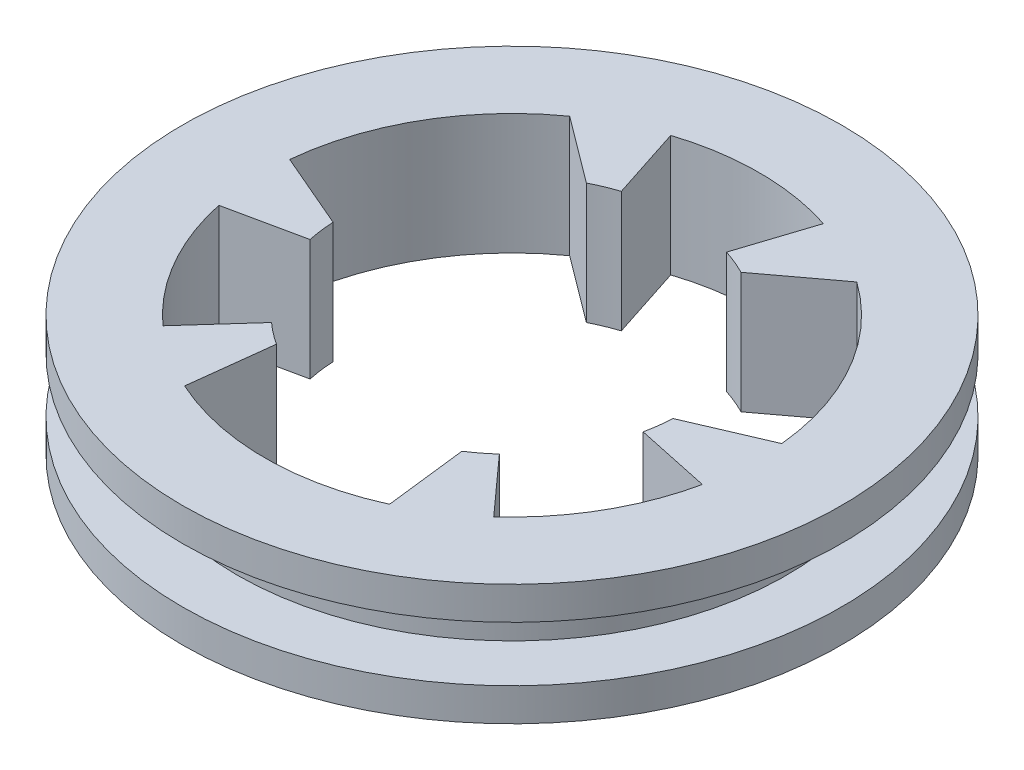
from build123d import *

# Parameters (mm, degrees)
CUT_EXTRUDE1_REACH = 13


with BuildPart() as part:
    # Sketch2 → Revolve1 (revolve)
    with BuildSketch(Plane.XY):
        Polygon((-25, 2.5), (-25, -2.5), (-30, -2.5), (-30, -5.5), (0, -5.5), (0, 5.5), (-30, 5.5), (-30, 2.5), align=None)
    revolve(axis=Axis((0, 19.987411147, 0), (0, -1, 0)))

    # Sketch3 → Cut-Extrude1 (cut, up to next)
    with BuildSketch(Plane(origin=(0, 5.5, 0), x_dir=(1, 0, 0), z_dir=(0, 1, 0)), mode=Mode.PRIVATE) as cut_extrude1_sk1:
        with BuildLine():
            ThreePointArc((15.055438643, -16.720758573), (19.485571585, -11.25), (22.008321017, -4.678013043))
            Line((22.008321017, -4.678013043), (15.161287811, -3.222631208))
            ThreePointArc((15.161287811, -3.222631208), (15.367467985, -2.022604196), (15.478816003, -0.810095759))
            Line((15.478816003, -0.810095759), (22.395997522, 2.160855156))
            ThreePointArc((22.395997522, 2.160855156), (19.485571585, 11.25), (13.06935422, 18.315075219))
            Line((13.06935422, 18.315075219), (7.037844495, 13.810095759))
            ThreePointArc((7.037844495, 13.810095759), (5.932107377, 14.319919765), (4.789763413, 14.741376003))
            Line((4.789763413, 14.741376003), (6.952882373, 21.398771617))
            ThreePointArc((6.952882373, 21.398771617), (0, 22.5), (-6.952882373, 21.398771617))
            Line((-6.952882373, 21.398771617), (-4.789763413, 14.741376003))
            ThreePointArc((-4.789763413, 14.741376003), (-5.932107377, 14.319919765), (-7.037844495, 13.810095759))
            Line((-7.037844495, 13.810095759), (-13.06935422, 18.315075219))
            ThreePointArc((-13.06935422, 18.315075219), (-19.485571585, 11.25), (-22.395997522, 2.160855156))
            Line((-22.395997522, 2.160855156), (-15.478816003, -0.810095759))
            ThreePointArc((-15.478816003, -0.810095759), (-15.367467985, -2.022604196), (-15.161287811, -3.222631208))
            Line((-15.161287811, -3.222631208), (-22.008321017, -4.678013043))
            ThreePointArc((-22.008321017, -4.678013043), (-19.485571585, -11.25), (-15.055438643, -16.720758573))
            Line((-15.055438643, -16.720758573), (-10.371524399, -11.518744795))
            ThreePointArc((-10.371524399, -11.518744795), (-9.435360608, -12.297315569), (-8.440971508, -13))
            Line((-8.440971508, -13), (-9.326643302, -20.475930375))
            ThreePointArc((-9.326643302, -20.475930375), (0, -22.5), (9.326643302, -20.475930375))
            Line((9.326643302, -20.475930375), (8.440971508, -13))
            ThreePointArc((8.440971508, -13), (9.435360608, -12.297315569), (10.371524399, -11.518744795))
            Line((10.371524399, -11.518744795), (15.055438643, -16.720758573))
        make_face()
    cut_extrude1_tool1 = extrude(cut_extrude1_sk1.sketch, amount=-CUT_EXTRUDE1_REACH, mode=Mode.PRIVATE) & part.part
    add(cut_extrude1_tool1.solids().sort_by_distance((0, 5.5, 0))[0], mode=Mode.SUBTRACT)


solid = part.part
